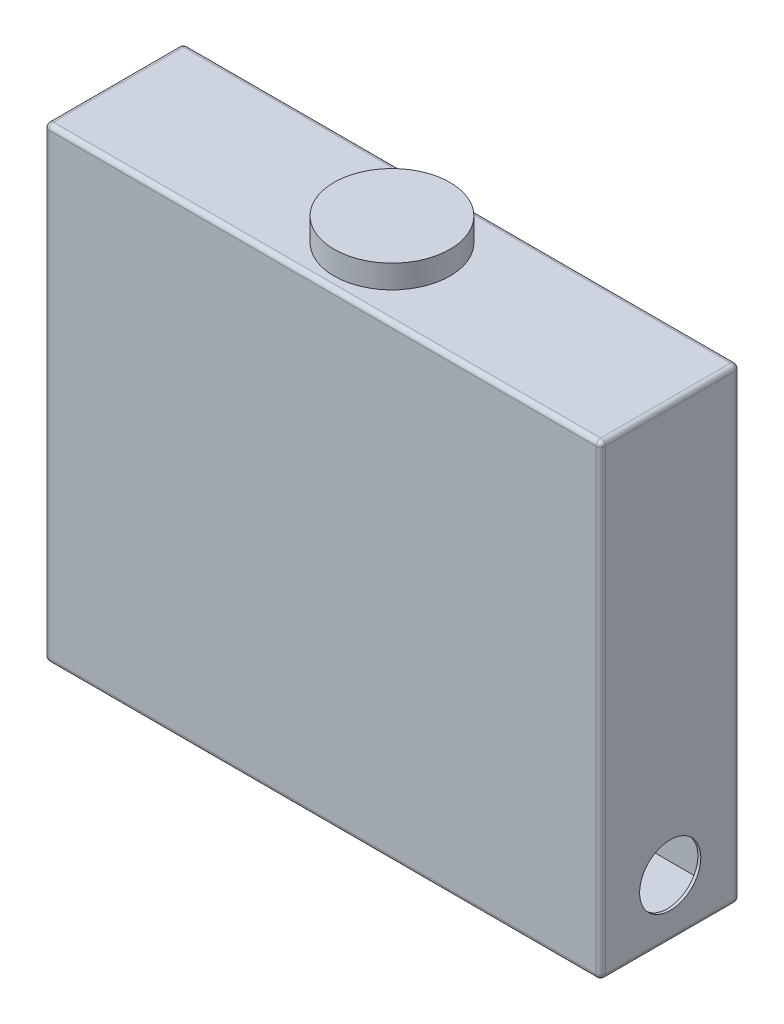
from build123d import *

# Parameters (mm, degrees)
SKETCH1_W           = 304.8
SKETCH1_H           = 76.2
BOSS_EXTRUDE1_DEPTH = 254
SHELL1_T            = -1.5875
SKETCH2_W           = 304.8
SKETCH2_H           = 76.2
BOSS_EXTRUDE2_DEPTH = 1.5875
FILLET1_R           = 2.54
CUT_EXTRUDE1_REACH  = 306.8
SKETCH3_R           = 16.764
CUT_EXTRUDE2_REACH  = 257.588
SKETCH4_R           = 28.575
SKETCH5_R           = 31.75
BOSS_EXTRUDE3_DEPTH = 12.7


with BuildPart() as part:
    # Sketch1 → Boss-Extrude1 (new body)
    with BuildSketch(Plane(origin=(0, 0, 0), x_dir=(1, 0, 0), z_dir=(0, 1, 0))):
        with Locations((152.4, 38.1)):
            Rectangle(SKETCH1_W, SKETCH1_H)
    extrude(amount=BOSS_EXTRUDE1_DEPTH)

    # Shell1
    shell1_openings = [part.faces().sort_by_distance(p)[0] for p in [
        (152.4, 254, -38.1),
    ]]
    offset(amount=SHELL1_T, openings=shell1_openings, kind=Kind.INTERSECTION)

    # Sketch2 → Boss-Extrude2 (add)
    with BuildSketch(Plane(origin=(0, 254, 0), x_dir=(1, 0, 0), z_dir=(0, 1, 0))):
        with Locations((152.4, 38.1)):
            Rectangle(SKETCH2_W, SKETCH2_H)
    extrude(amount=BOSS_EXTRUDE2_DEPTH)

    # Fillet1
    fillet1_edges = [part.edges().sort_by_distance(p)[0] for p in [
        (0, 255.5875, -38.1),
        (152.4, 255.5875, 0),
        (304.8, 255.5875, -38.1),
        (152.4, 255.5875, -76.2),
        (152.4, 0, -76.2),
        (304.8, 0, -38.1),
        (152.4, 0, 0),
        (0, 0, -38.1),
        (0, 127.79375, -76.2),
        (304.8, 127.79375, -76.2),
        (304.8, 127.79375, 0),
        (0, 127.79375, 0),
    ]]
    fillet(fillet1_edges, radius=FILLET1_R)

    # Sketch3 → Cut-Extrude1 (cut, up to next)
    with BuildSketch(Plane(origin=(304.8, 0, 0), x_dir=(0, 0, -1), z_dir=(1, 0, 0)), mode=Mode.PRIVATE) as cut_extrude1_sk1:
        with Locations((38.1, 31.75)):
            Circle(SKETCH3_R)
    cut_extrude1_tool1 = extrude(cut_extrude1_sk1.sketch, amount=-CUT_EXTRUDE1_REACH, mode=Mode.PRIVATE) & part.part
    add(cut_extrude1_tool1.solids().sort_by_distance((304.8, 31.75, -38.1))[0], mode=Mode.SUBTRACT)

    # Sketch4 → Cut-Extrude2 (cut, up to next)
    with BuildSketch(Plane(origin=(0, 255.5875, 0), x_dir=(1, 0, 0), z_dir=(0, 1, 0)), mode=Mode.PRIVATE) as cut_extrude2_sk1:
        with Locations((152.4, 38.1)):
            Circle(SKETCH4_R)
    cut_extrude2_tool1 = extrude(cut_extrude2_sk1.sketch, amount=-CUT_EXTRUDE2_REACH, mode=Mode.PRIVATE) & part.part
    add(cut_extrude2_tool1.solids().sort_by_distance((152.4, 255.5875, -38.1))[0], mode=Mode.SUBTRACT)


with BuildPart() as body_2:
    # Sketch5 → Boss-Extrude3 (new body)
    with BuildSketch(Plane(origin=(0, 255.5875, 0), x_dir=(1, 0, 0), z_dir=(0, 1, 0))):
        with Locations((152.4, 38.1)):
            Circle(SKETCH5_R)
    extrude(amount=BOSS_EXTRUDE3_DEPTH)


solid = Compound([part.part, body_2.part])
